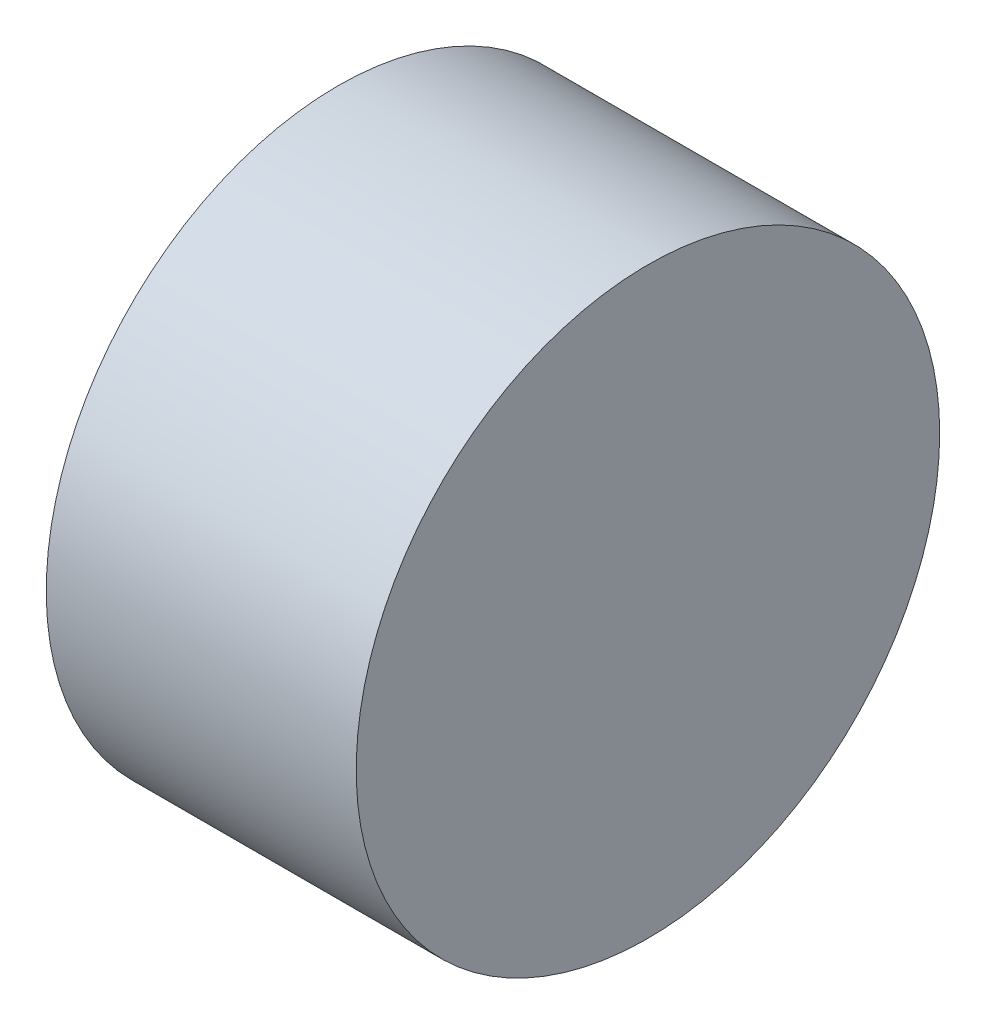
from build123d import *

# Parameters (mm, degrees)
SKETCH1_R           = 4
BOSS_EXTRUDE1_DEPTH = 3.25
SKETCH2_R           = 4
BOSS_EXTRUDE2_DEPTH = 1


with BuildPart() as part:
    # Sketch1 → Boss-Extrude1 (new body)
    with BuildSketch(Plane(origin=(0, 0, 0), x_dir=(0, 0, -1), z_dir=(1, 0, 0))):
        Circle(SKETCH1_R)
        with BuildLine():
            Line((-1.527350647, -2.157), (1.527350647, -2.157))
            ThreePointArc((1.527350647, -2.157), (0, 2.643), (-1.527350647, -2.157))
        make_face(mode=Mode.SUBTRACT)
    extrude(amount=-BOSS_EXTRUDE1_DEPTH)

    # Sketch2 → Boss-Extrude2 (add)
    with BuildSketch(Plane(origin=(0, 0, 0), x_dir=(0, 0, -1), z_dir=(1, 0, 0))):
        Circle(SKETCH2_R)
    extrude(amount=BOSS_EXTRUDE2_DEPTH)


solid = part.part
